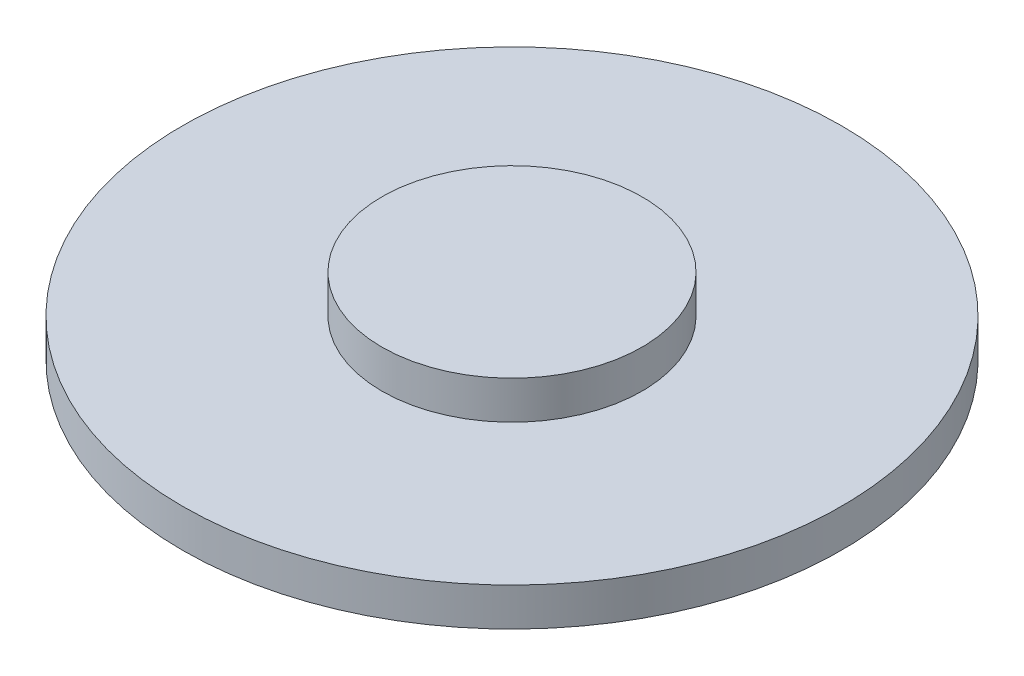
from build123d import *

# Parameters (mm, degrees)
SKETCH1_R           = 10.0965
BOSS_EXTRUDE1_DEPTH = 1.1684
SKETCH2_R           = 3.9878
BOSS_EXTRUDE2_DEPTH = 1.1684


with BuildPart() as part:
    # Sketch1 → Boss-Extrude1 (new body)
    with BuildSketch(Plane(origin=(0, 0, 0), x_dir=(1, 0, 0), z_dir=(0, 1, 0))):
        Circle(SKETCH1_R)
    extrude(amount=BOSS_EXTRUDE1_DEPTH)

    # Sketch2 → Boss-Extrude2 (add)
    with BuildSketch(Plane(origin=(0, 1.1684, 0), x_dir=(1, 0, 0), z_dir=(0, 1, 0))):
        Circle(SKETCH2_R)
    extrude(amount=BOSS_EXTRUDE2_DEPTH)


solid = part.part
